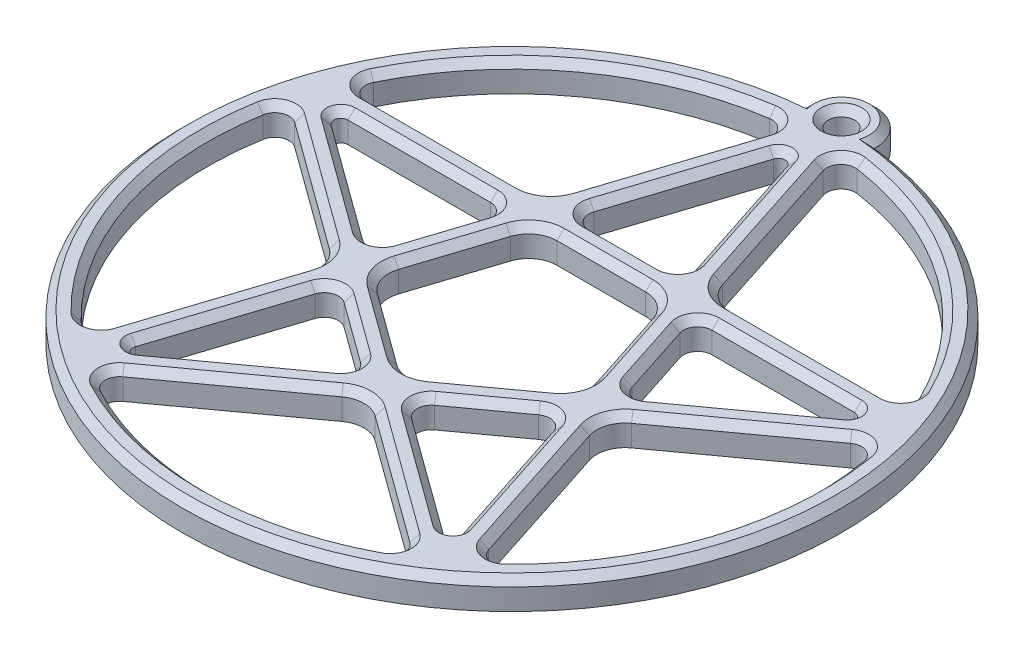
from build123d import *

# Parameters (mm, degrees)
SKETCH1_R           = 1.852456066
BOSS_EXTRUDE1_DEPTH = 4
CHAMFER1_SIZE       = 1


with BuildPart() as part:
    # Sketch1 → Boss-Extrude1 (new body)
    with BuildSketch(Plane(origin=(0, 0, 0), x_dir=(1, 0, 0), z_dir=(0, 1, 0))):
        with BuildLine():
            ThreePointArc((-4.845804171, 46.098557409), (0, 51.205005222), (4.845804171, 46.098557409))
            ThreePointArc((4.845804171, 46.098557409), (0, -46.352549156), (-4.845804171, 46.098557409))
        make_face()
        with Locations(Location((0, 46.352549156, 0), (0, 0, 270))):  # turned: the seam where the file's is
            Circle(SKETCH1_R, mode=Mode.SUBTRACT)
        with BuildLine():
            Line((-10.033402208, 9.809793399), (-13.883244786, -2.038803723))
            ThreePointArc((-13.883244786, -2.038803723), (-13.883244786, -4.510939678), (-12.43015973, -6.510939678))
            Line((-12.43015973, -6.510939678), (-2.351141009, -13.833775419))
            ThreePointArc((-2.351141009, -13.833775419), (0, -14.597707442), (2.351141009, -13.833775419))
            Line((2.351141009, -13.833775419), (12.43015973, -6.510939678))
            ThreePointArc((12.43015973, -6.510939678), (13.883244786, -4.510939678), (13.883244786, -2.038803723))
            Line((13.883244786, -2.038803723), (10.033402208, 9.809793399))
            ThreePointArc((10.033402208, 9.809793399), (8.580317152, 11.809793399), (6.229176142, 12.573725422))
            Line((6.229176142, 12.573725422), (-6.229176142, 12.573725422))
            ThreePointArc((-6.229176142, 12.573725422), (-8.580317152, 11.809793399), (-10.033402208, 9.809793399))
        make_face(mode=Mode.SUBTRACT)
        with BuildLine():
            Line((39.087870417, 8.530782914), (21.246938514, -4.431412853))
            ThreePointArc((21.246938514, -4.431412853), (19.793853458, -6.431412853), (19.793853458, -8.903548808))
            Line((19.793853458, -8.903548808), (26.608483054, -29.876822128))
            ThreePointArc((26.608483054, -29.876822128), (28.031122427, -31.200463964), (29.906376603, -30.69119756))
            ThreePointArc((29.906376603, -30.69119756), (40.755196115, -13.242165942), (42.234600213, 7.251173287))
            ThreePointArc((42.234600213, 7.251173287), (41.016826997, 8.765425211), (39.087870417, 8.530782914))
        make_face(mode=Mode.SUBTRACT)
        with BuildLine():
            Line((36.637019829, 16.073725422), (14.584415214, 16.073725422))
            ThreePointArc((14.584415214, 16.073725422), (12.233274205, 16.837657444), (10.780189149, 18.837657444))
            Line((10.780189149, 18.837657444), (3.965559553, 39.810930764))
            ThreePointArc((3.965559553, 39.810930764), (4.338481832, 41.717985947), (6.154933612, 42.40822752))
            ThreePointArc((6.154933612, 42.40822752), (25.188096417, 34.66844052), (38.430642043, 18.958552724))
            ThreePointArc((38.430642043, 18.958552724), (38.335497766, 17.017708046), (36.637019829, 16.073725422))
        make_face(mode=Mode.SUBTRACT)
        with BuildLine():
            Line((-3.965559553, 39.810930764), (-10.780189149, 18.837657444))
            ThreePointArc((-10.780189149, 18.837657444), (-12.233274205, 16.837657444), (-14.584415214, 16.073725422))
            Line((-14.584415214, 16.073725422), (-36.637019829, 16.073725422))
            ThreePointArc((-36.637019829, 16.073725422), (-38.335497766, 17.017708046), (-38.430642043, 18.958552724))
            ThreePointArc((-38.430642043, 18.958552724), (-25.188096417, 34.66844052), (-6.154933612, 42.40822752))
            ThreePointArc((-6.154933612, 42.40822752), (-4.338481832, 41.717985947), (-3.965559553, 39.810930764))
        make_face(mode=Mode.SUBTRACT)
        with BuildLine():
            Line((-39.087870417, 8.530782914), (-21.246938514, -4.431412853))
            ThreePointArc((-21.246938514, -4.431412853), (-19.793853458, -6.431412853), (-19.793853458, -8.903548808))
            Line((-19.793853458, -8.903548808), (-26.608483054, -29.876822128))
            ThreePointArc((-26.608483054, -29.876822128), (-28.031122427, -31.200463964), (-29.906376603, -30.69119756))
            ThreePointArc((-29.906376603, -30.69119756), (-40.755196115, -13.242165942), (-42.234600213, 7.251173287))
            ThreePointArc((-42.234600213, 7.251173287), (-41.016826997, 8.765425211), (-39.087870417, 8.530782914))
        make_face(mode=Mode.SUBTRACT)
        with BuildLine():
            Line((-20.192072912, -34.538616973), (-2.351141009, -21.576421206))
            ThreePointArc((-2.351141009, -21.576421206), (0, -20.812489183), (2.351141009, -21.576421206))
            Line((2.351141009, -21.576421206), (20.192072912, -34.538616973))
            ThreePointArc((20.192072912, -34.538616973), (21.011311363, -36.30065524), (19.947484821, -37.926755971))
            ThreePointArc((19.947484821, -37.926755971), (0, -42.852549156), (-19.947484821, -37.926755971))
            ThreePointArc((-19.947484821, -37.926755971), (-21.011311363, -36.30065524), (-20.192072912, -34.538616973))
        make_face(mode=Mode.SUBTRACT)
        with BuildLine():
            Line((-15.56822788, 12.573725422), (-35.620264195, 12.573725422))
            ThreePointArc((-35.620264195, 12.573725422), (-36.571320711, 11.882742416), (-36.208049447, 10.764708428))
            Line((-36.208049447, 10.764708428), (-19.985611297, -1.021582797))
            ThreePointArc((-19.985611297, -1.021582797), (-18.192006803, -1.30566184), (-16.90792776, -0.021582797))
            Line((-16.90792776, -0.021582797), (-13.666114848, 9.955691433))
            ThreePointArc((-13.666114848, 9.955691433), (-13.950193891, 11.749295926), (-15.56822788, 12.573725422))
        make_face(mode=Mode.SUBTRACT)
        with BuildLine():
            Line((-7.147476509, 18.691759411), (-0.951056516, 37.762379212))
            ThreePointArc((-0.951056516, 37.762379212), (0, 38.453362218), (0.951056516, 37.762379212))
            Line((0.951056516, 37.762379212), (7.147476509, 18.691759411))
            ThreePointArc((7.147476509, 18.691759411), (6.863397465, 16.898154917), (5.245363477, 16.073725422))
            Line((5.245363477, 16.073725422), (-5.245363477, 16.073725422))
            ThreePointArc((-5.245363477, 16.073725422), (-6.863397465, 16.898154917), (-7.147476509, 18.691759411))
        make_face(mode=Mode.SUBTRACT)
        with BuildLine():
            Line((15.56822788, 12.573725422), (35.620264195, 12.573725422))
            ThreePointArc((35.620264195, 12.573725422), (36.571320711, 11.882742416), (36.208049447, 10.764708428))
            Line((36.208049447, 10.764708428), (19.985611297, -1.021582797))
            ThreePointArc((19.985611297, -1.021582797), (18.192006803, -1.30566184), (16.90792776, -0.021582797))
            Line((16.90792776, -0.021582797), (13.666114848, 9.955691433))
            ThreePointArc((13.666114848, 9.955691433), (13.950193891, 11.749295926), (15.56822788, 12.573725422))
        make_face(mode=Mode.SUBTRACT)
        with BuildLine():
            Line((22.965590477, -29.991389537), (16.769170484, -10.920769735))
            ThreePointArc((16.769170484, -10.920769735), (15.48509144, -9.636690691), (13.691486947, -9.920769735))
            Line((13.691486947, -9.920769735), (5.204310558, -16.087064324))
            ThreePointArc((5.204310558, -16.087064324), (4.379881063, -17.705098312), (5.204310558, -19.323132301))
            Line((5.204310558, -19.323132301), (21.426748708, -31.109423525))
            ThreePointArc((21.426748708, -31.109423525), (22.602319213, -31.109423525), (22.965590477, -29.991389537))
        make_face(mode=Mode.SUBTRACT)
        with BuildLine():
            Line((-22.965590477, -29.991389537), (-16.769170484, -10.920769735))
            ThreePointArc((-16.769170484, -10.920769735), (-15.48509144, -9.636690691), (-13.691486947, -9.920769735))
            Line((-13.691486947, -9.920769735), (-5.204310558, -16.087064324))
            ThreePointArc((-5.204310558, -16.087064324), (-4.379881063, -17.705098312), (-5.204310558, -19.323132301))
            Line((-5.204310558, -19.323132301), (-21.426748708, -31.109423525))
            ThreePointArc((-21.426748708, -31.109423525), (-22.602319213, -31.109423525), (-22.965590477, -29.991389537))
        make_face(mode=Mode.SUBTRACT)
    extrude(amount=BOSS_EXTRUDE1_DEPTH)

    # Chamfer1
    chamfer1_edges = [part.edges().sort_by_distance(p)[0] for p in [
        (21.011311363, 4, 36.30065524),
        (11.271606961, 4, 28.057519089),
        (-19.793853458, 4, 6.431412853),
        (-30.167404466, 4, -2.049685031),
        (-41.016826997, 4, -8.765425211),
        (-40.755196115, 4, 13.242165942),
        (-28.031122427, 4, 31.200463964),
        (-23.201168256, 4, 19.390185468),
        (-18.192006803, 4, 1.30566184),
        (-15.287021304, 4, -4.967054318),
        (-13.950193891, 4, -11.749295926),
        (-25.594246037, 4, -12.573725422),
        (-36.571320711, 4, -11.882742416),
        (-28.096830372, 4, -4.871562815),
        (-6.863397465, 4, -16.898154917),
        (0, 4, -16.073725422),
        (6.863397465, 4, -16.898154917),
        (4.049266513, 4, -28.227069312),
        (0, 4, -38.453362218),
        (-4.049266513, 4, -28.227069312),
        (13.950193891, 4, -11.749295926),
        (15.287021304, 4, -4.967054318),
        (18.192006803, 4, 1.30566184),
        (28.096830372, 4, -4.871562815),
        (36.571320711, 4, -11.882742416),
        (25.594246037, 4, -12.573725422),
        (15.48509144, 4, 9.636690691),
        (9.447898752, 4, 13.003917029),
        (4.379881063, 4, 17.705098312),
        (13.315529633, 4, 25.216277913),
        (-13.883244786, 4, 4.510939678),
        (22.602319213, 4, 31.109423525),
        (19.86738048, 4, 20.456079636),
        (-7.390650369, 4, 10.172357549),
        (0, 4, 14.597707442),
        (7.390650369, 4, 10.172357549),
        (13.883244786, 4, 4.510939678),
        (11.958323497, 4, -3.885494838),
        (-4.379881063, 4, 17.705098312),
        (-9.447898752, 4, 13.003917029),
        (-15.48509144, 4, 9.636690691),
        (8.580317152, 4, -11.809793399),
        (-19.86738048, 4, 20.456079636),
        (-22.602319213, 4, 31.109423525),
        (-13.315529633, 4, 25.216277913),
        (0, 4, -12.573725422),
        (-8.580317152, 4, -11.809793399),
        (-11.958323497, 4, -3.885494838),
        (0, 4, -48.205005222),
        (0, 4, 46.352549156),
        (-12.233274205, 4, -16.837657444),
        (-7.372874351, 4, -29.324294104),
        (-4.338481832, 4, -41.717985947),
        (-25.188096417, 4, -34.66844052),
        (-38.335497766, 4, -17.017708046),
        (-25.610717522, 4, -16.073725422),
        (12.233274205, 4, -16.837657444),
        (25.610717522, 4, -16.073725422),
        (38.335497766, 4, -17.017708046),
        (25.188096417, 4, -34.66844052),
        (4.338481832, 4, -41.717985947),
        (7.372874351, 4, -29.324294104),
        (0, 4, -51.205005222),
        (19.793853458, 4, 6.431412853),
        (23.201168256, 4, 19.390185468),
        (28.031122427, 4, 31.200463964),
        (40.755196115, 4, 13.242165942),
        (41.016826997, 4, -8.765425211),
        (30.167404466, 4, -2.049685031),
        (0, 4, 20.812489183),
        (-11.271606961, 4, 28.057519089),
        (-21.011311363, 4, 36.30065524),
        (0, 4, 42.852549156),
    ]]
    chamfer(chamfer1_edges, length=CHAMFER1_SIZE)


solid = part.part
